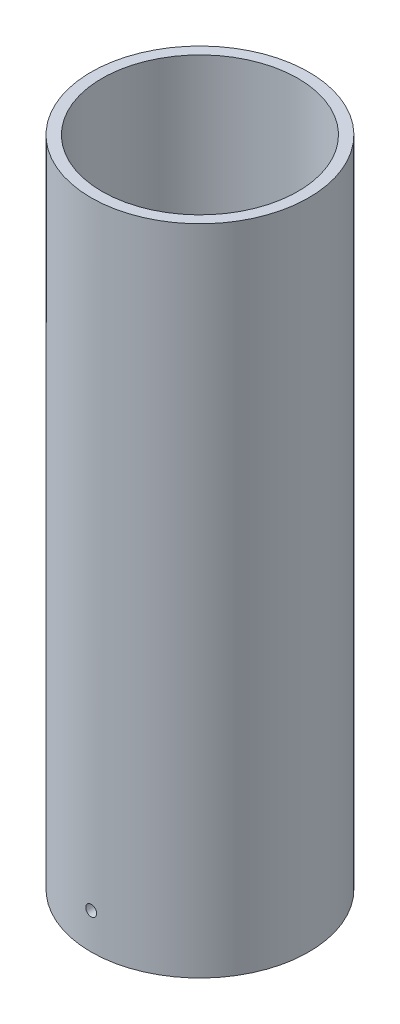
from build123d import *

# Parameters (mm, degrees)
SKETCH1_R               = 30
SKETCH1_R_2             = 25
BOSS_EXTRUDE1_DEPTH     = 180
SKETCH2_R               = 1.5
CUT_EXTRUDE1_DEPTH      = 31
CUT_EXTRUDE1_DEPTH_BACK = 31
SKETCH3_R               = 27
SKETCH3_R_2             = 19.569844271
CUT_EXTRUDE2_DEPTH      = 160


with BuildPart() as part:
    # Sketch1 → Boss-Extrude1 (new body)
    with BuildSketch(Plane(origin=(0, 0, 0), x_dir=(1, 0, 0), z_dir=(0, 1, 0))):
        Circle(SKETCH1_R)
        Circle(SKETCH1_R_2, mode=Mode.SUBTRACT)
    extrude(amount=BOSS_EXTRUDE1_DEPTH)

    # Sketch2 → Cut-Extrude1 (cut, two sides)
    with BuildSketch(Plane.XY) as cut_extrude1_sk:
        with Locations((0, 9.9)):
            Circle(SKETCH2_R)
    extrude(amount=CUT_EXTRUDE1_DEPTH, mode=Mode.SUBTRACT)
    extrude(cut_extrude1_sk.sketch, amount=-CUT_EXTRUDE1_DEPTH_BACK, mode=Mode.SUBTRACT)

    # Sketch3 → Cut-Extrude2 (cut)
    with BuildSketch(Plane(origin=(0, 180, 0), x_dir=(1, 0, 0), z_dir=(0, 1, 0))):
        Circle(SKETCH3_R)
        Circle(SKETCH3_R_2, mode=Mode.SUBTRACT)
    extrude(amount=-CUT_EXTRUDE2_DEPTH, mode=Mode.SUBTRACT)


solid = part.part
